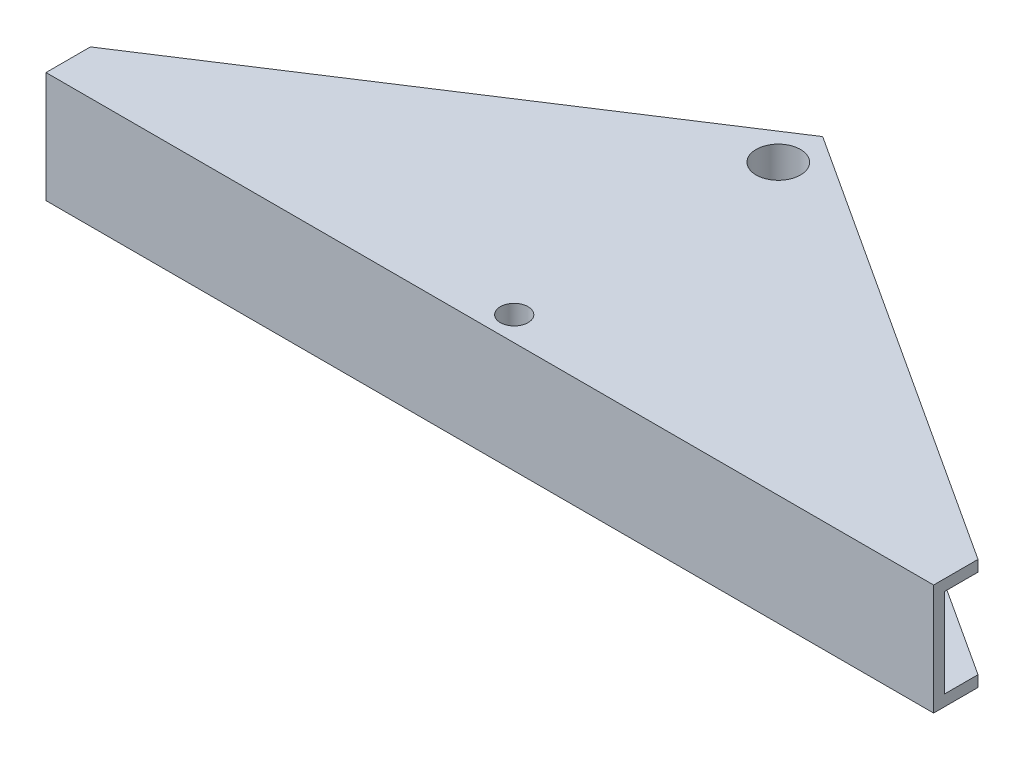
from build123d import *

# Parameters (mm, degrees)
SKETCH1_R           = 2
SKETCH1_R_2         = 1.25
BOSS_EXTRUDE1_DEPTH = 10
CUT_EXTRUDE1_DEPTH  = 8


with BuildPart() as part:
    # Sketch1 → Boss-Extrude1 (new body)
    with BuildSketch(Plane(origin=(0, 0, 0), x_dir=(1, 0, 0), z_dir=(0, 1, 0))):
        Polygon((0, 26), (-40, 0), (-40, -4), (40, -4), (40, 0), align=None)
        with Locations((0, 22)):
            Circle(SKETCH1_R, mode=Mode.SUBTRACT)
        with Locations((0, -1.8)):
            Circle(SKETCH1_R_2, mode=Mode.SUBTRACT)
    extrude(amount=BOSS_EXTRUDE1_DEPTH)

    # Sketch2 → Cut-Extrude1 (cut)
    with BuildSketch(Plane(origin=(0, 9, 0), x_dir=(1, 0, 0), z_dir=(0, 1, 0))):
        Polygon((-3, 26), (-7.746877636, 2), (-40, -3), (-40, 3.063809347), align=None)
    cut_extrude1 = extrude(amount=-CUT_EXTRUDE1_DEPTH, mode=Mode.SUBTRACT)

    # Mirror1: Cut-Extrude1 across plane
    add(cut_extrude1.mirror(Plane(origin=(0, 0, 0), x_dir=(0, 0, 1), z_dir=(1, 0, 0))), mode=Mode.SUBTRACT)


solid = part.part
